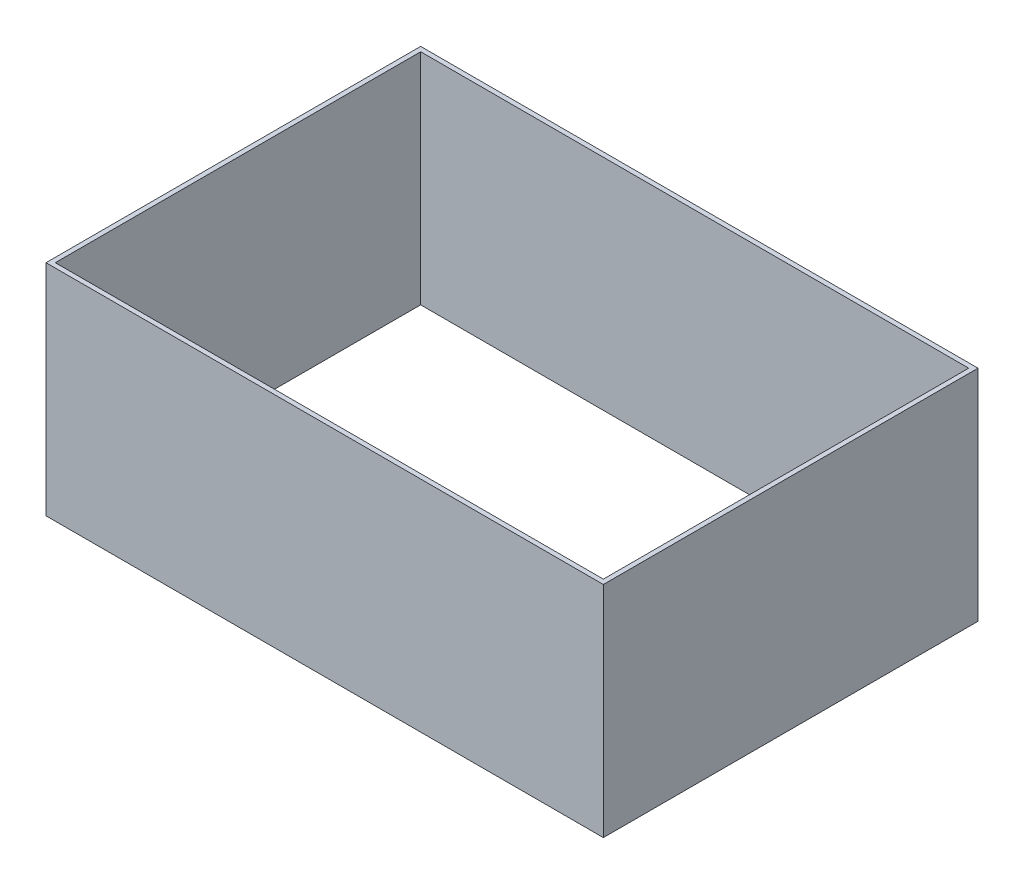
from build123d import *

# Parameters (mm, degrees)
SKETCH1_W           = 305.08
SKETCH1_H           = 205.08
SKETCH1_W_2         = 300
SKETCH1_H_2         = 200
BOSS_EXTRUDE1_DEPTH = 120


with BuildPart() as part:
    # Sketch1 → Boss-Extrude1 (new body)
    with BuildSketch(Plane(origin=(0, 0, 0), x_dir=(1, 0, 0), z_dir=(0, 1, 0))):
        Rectangle(SKETCH1_W, SKETCH1_H)
        Rectangle(SKETCH1_W_2, SKETCH1_H_2, mode=Mode.SUBTRACT)
    extrude(amount=BOSS_EXTRUDE1_DEPTH)


solid = part.part
